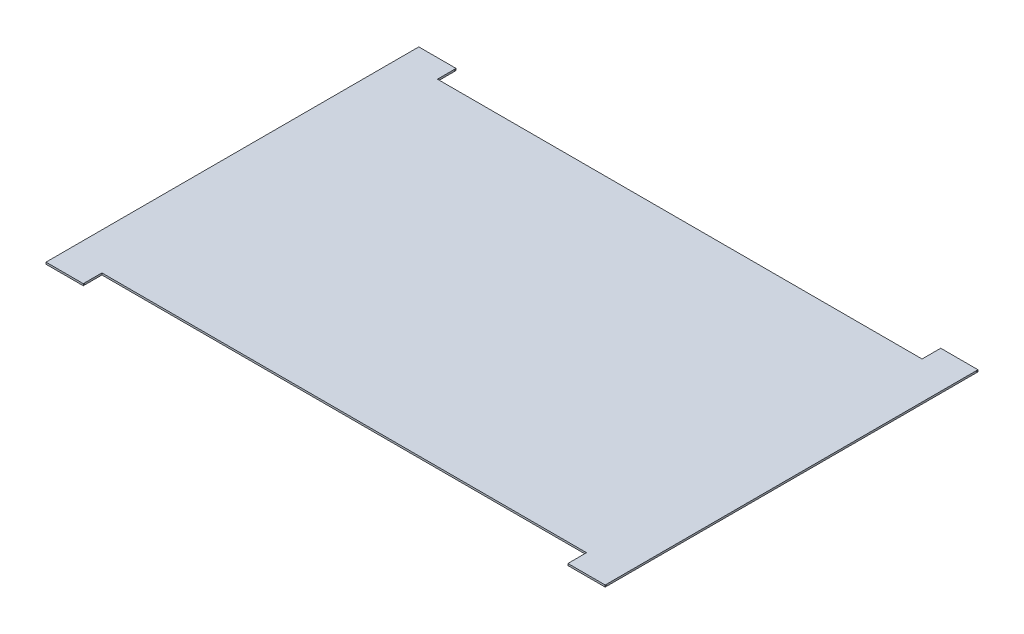
from build123d import *

# Parameters (mm, degrees)
SALIENTE_EXTRUIR1_DEPTH = 0.1
CROQUIS2_R              = 0.025
CORTAR_EXTRUIR1_DEPTH   = 30


with BuildPart() as part:
    # Croquis1 → Saliente-Extruir1 (new body)
    with BuildSketch(Plane(origin=(0, 0, 0), x_dir=(1, 0, 0), z_dir=(0, 1, 0))):
        Polygon((0, 20), (0, 0), (2, 0), (2, 1), (28, 1), (28, 0), (30, 0), (30, 20), (28, 20), (28, 19), (2, 19), (2, 20), align=None)
    extrude(amount=SALIENTE_EXTRUIR1_DEPTH)

    # Croquis2 → Cortar-Extruir1 (cut)
    with BuildSketch(Plane(origin=(30, 0, 0), x_dir=(0, 0, -1), z_dir=(1, 0, 0))):
        with Locations((19.95, 0.05)):
            Circle(CROQUIS2_R)
        with Locations((0.05, 0.05)):
            Circle(CROQUIS2_R)
    extrude(amount=-CORTAR_EXTRUIR1_DEPTH, mode=Mode.SUBTRACT)


solid = part.part
